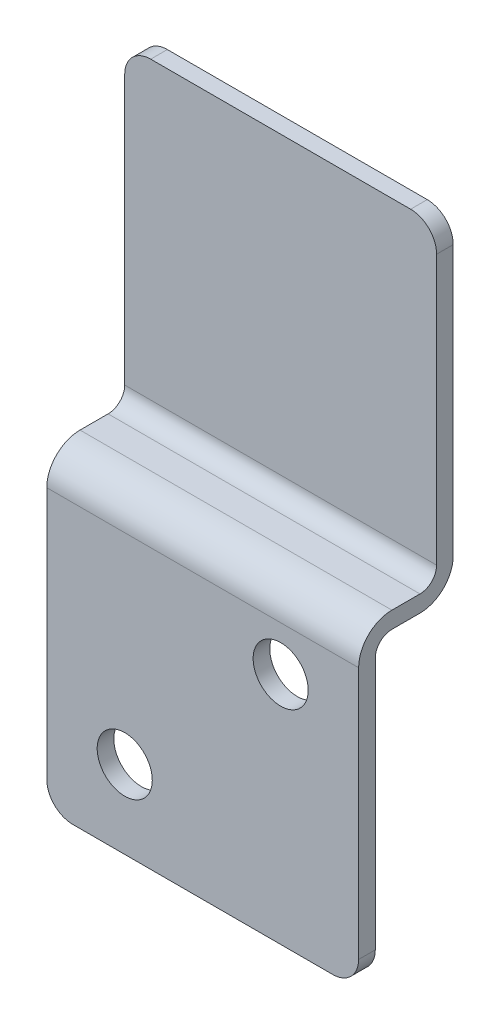
from build123d import *

# Parameters (mm, degrees)
BOSS_EXTRUDE1_DEPTH = 38.1
FILLET1_R           = 2.032
FILLET2_R           = 4.064
FILLET3_R           = 3.175
SKETCH2_R           = 3.3655
CUT_EXTRUDE1_DEPTH  = 12.557


with BuildPart() as part:
    # Sketch1 → Boss-Extrude1 (new body)
    with BuildSketch(Plane(origin=(0, 0, 0), x_dir=(0, 0, -1), z_dir=(1, 0, 0))):
        Polygon((0, 0), (0, -38.1), (-9.525, -38.1), (-9.525, -76.2), (-7.493, -76.2), (-7.493, -40.132), (2.032, -40.132), (2.032, 0), align=None)
    extrude(amount=BOSS_EXTRUDE1_DEPTH)

    # Fillet1
    fillet1_edges = [part.edges().sort_by_distance(p)[0] for p in [
        (19.05, -40.132, 7.493),
        (19.05, -38.1, 0),
    ]]
    fillet(fillet1_edges, radius=FILLET1_R)

    # Fillet2
    fillet2_edges = [part.edges().sort_by_distance(p)[0] for p in [
        (19.05, -40.132, -2.032),
        (19.05, -38.1, 9.525),
    ]]
    fillet(fillet2_edges, radius=FILLET2_R)

    # Fillet3
    fillet3_edges = [part.edges().sort_by_distance(p)[0] for p in [
        (0, 0, -1.016),
        (38.1, -76.2, 8.509),
        (38.1, 0, -1.016),
        (0, -76.2, 8.509),
    ]]
    fillet(fillet3_edges, radius=FILLET3_R)

    # Sketch2 → Cut-Extrude1 (cut, through all)
    with BuildSketch(Plane.XY.offset(9.525)):
        with Locations((9.525, -66.675)):
            Circle(SKETCH2_R)
        with Locations((28.575, -47.625)):
            Circle(SKETCH2_R)
    extrude(amount=-CUT_EXTRUDE1_DEPTH, mode=Mode.SUBTRACT)


solid = part.part
